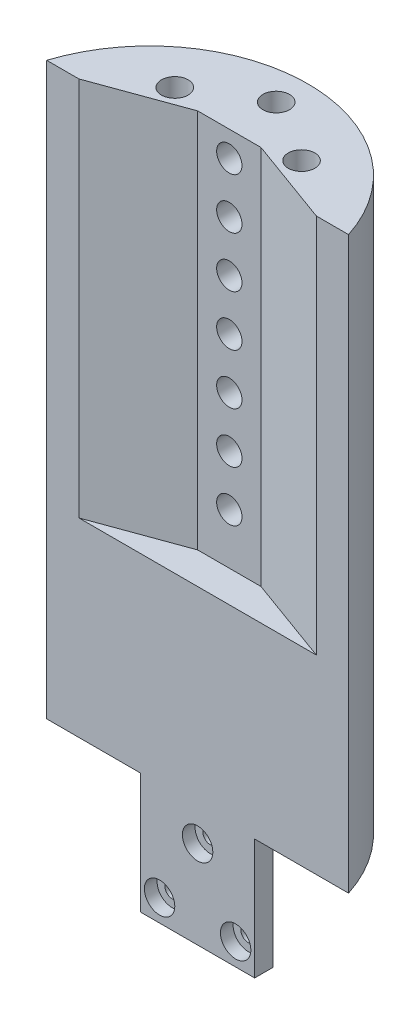
from build123d import *

# Parameters (mm, degrees)
BOSS_EXTRUDE1_DEPTH   = 57.15
SKETCH2_W             = 22.86
SKETCH2_H             = 3.683
BOSS_EXTRUDE2_DEPTH   = 24.13
SKETCH3_R             = 3.048
CUT_EXTRUDE1_DEPTH    = 2.54
F_3_0MM_DOWEL_HOLE1_D = 3
SKETCH6_W             = 12.7
SKETCH6_H             = 76.2
CUT_EXTRUDE2_DEPTH    = 6.35
CUT_EXTRUDE3_DEPTH    = 5.08
SKETCH7_R             = 2.54
CUT_EXTRUDE4_DEPTH    = 6.35
CUT_EXTRUDE5_DEPTH    = 76.2


with BuildPart() as part:
    # Sketch1 → Boss-Extrude1 (new body, symmetric)
    with BuildSketch(Plane(origin=(0, 0, 0), x_dir=(1, 0, 0), z_dir=(0, 1, 0))):
        with BuildLine():
            ThreePointArc((30.247337007, 9.652), (0, 31.75), (-30.247337007, 9.652))
            Line((-30.247337007, 9.652), (30.247337007, 9.652))
        make_face()
    extrude(amount=BOSS_EXTRUDE1_DEPTH, both=True)

    # Sketch2 → Boss-Extrude2 (add)
    with BuildSketch(Plane.XZ.offset(57.15)):
        with Locations((0, -11.4935)):
            Rectangle(SKETCH2_W, SKETCH2_H)
    extrude(amount=BOSS_EXTRUDE2_DEPTH)

    # Sketch3 → Cut-Extrude1 (cut)
    with BuildSketch(Plane.XY.offset(-9.652)):
        with Locations((0, -63.641247378)):
            Circle(SKETCH3_R)
        with Locations((-7.62, -76.839474532)):
            Circle(SKETCH3_R)
        with Locations((7.62, -76.839474532)):
            Circle(SKETCH3_R)
    extrude(amount=-CUT_EXTRUDE1_DEPTH, mode=Mode.SUBTRACT)

    # Ø3.0mm Dowel Hole1 (through all)
    with Locations(Plane.XY.offset(-9.652)):
        with Locations((0, -63.641247378), (7.62, -76.839474532), (-7.62, -76.839474532)):
            Hole(F_3_0MM_DOWEL_HOLE1_D / 2)

    # Sketch6 → Cut-Extrude2 (cut)
    with BuildSketch(Plane.XY.offset(-9.652)):
        with Locations((0, 19.05)):
            Rectangle(SKETCH6_W, SKETCH6_H)
    extrude(amount=-CUT_EXTRUDE2_DEPTH, mode=Mode.SUBTRACT)

    # Sketch8 → Cut-Extrude3 (cut)
    with BuildSketch(Plane(origin=(0, 57.15, 0), x_dir=(1, 0, 0), z_dir=(0, 1, 0))):
        with BuildLine():
            Line((2.286933633, 24.02783982), (0, 25.4))
            Line((0, 25.4), (-2.286933633, 24.02783982))
            ThreePointArc((-2.286933633, 24.02783982), (0, 22.733), (2.286933633, 24.02783982))
        make_face()
        with BuildLine():
            Line((-2.286933633, 24.02783982), (0, 25.4))
            Line((0, 25.4), (2.286933633, 24.02783982))
            ThreePointArc((2.286933633, 24.02783982), (2.570227714, 24.688088137), (2.667, 25.4))
            ThreePointArc((2.667, 25.4), (-0.711911863, 27.970227714), (-2.286933633, 24.02783982))
        make_face()
        with BuildLine():
            ThreePointArc((-10.033, 17.78), (-10.129772286, 18.491911863), (-10.413066367, 19.15216018))
            Line((-10.413066367, 19.15216018), (-12.7, 17.78))
            Line((-12.7, 17.78), (-10.033, 17.78))
        make_face()
        with BuildLine():
            Line((-12.7, 17.78), (-10.413066367, 19.15216018))
            ThreePointArc((-10.413066367, 19.15216018), (-15.270227714, 17.068088137), (-10.033, 17.78))
            Line((-10.033, 17.78), (-12.7, 17.78))
        make_face()
        with BuildLine():
            ThreePointArc((15.367, 17.78), (13.411911863, 20.350227714), (10.413066367, 19.15216018))
            Line((10.413066367, 19.15216018), (12.7, 17.78))
            Line((12.7, 17.78), (10.033, 17.78))
            ThreePointArc((10.033, 17.78), (12.7, 15.113), (15.367, 17.78))
        make_face()
        with BuildLine():
            Line((12.7, 17.78), (10.413066367, 19.15216018))
            ThreePointArc((10.413066367, 19.15216018), (10.129772286, 18.491911863), (10.033, 17.78))
            Line((10.033, 17.78), (12.7, 17.78))
        make_face()
    extrude(amount=-CUT_EXTRUDE3_DEPTH, mode=Mode.SUBTRACT)

    # Sketch7 → Cut-Extrude4 (cut)
    with BuildSketch(Plane.XY.offset(-16.002)):
        with Locations((0, 52.07)):
            Circle(SKETCH7_R)
        with Locations((0, 41.91)):
            Circle(SKETCH7_R)
        with Locations((0, 31.75)):
            Circle(SKETCH7_R)
        with Locations((0, 21.59)):
            Circle(SKETCH7_R)
        with Locations((0, 11.43)):
            Circle(SKETCH7_R)
        with Locations((0, 1.27)):
            Circle(SKETCH7_R)
        with Locations((0, -8.89)):
            Circle(SKETCH7_R)
    extrude(amount=-CUT_EXTRUDE4_DEPTH, mode=Mode.SUBTRACT)

    # Sketch9 → Cut-Extrude5 (cut)
    with BuildSketch(Plane(origin=(0, 57.15, 0), x_dir=(1, 0, 0), z_dir=(0, 1, 0))):
        Polygon((6.35, 16.002), (23.796481614, 9.652), (6.35, 9.652), align=None)
        Polygon((-6.35, 16.002), (-23.796481614, 9.652), (-6.35, 9.652), align=None)
    extrude(amount=-CUT_EXTRUDE5_DEPTH, mode=Mode.SUBTRACT)


solid = part.part
